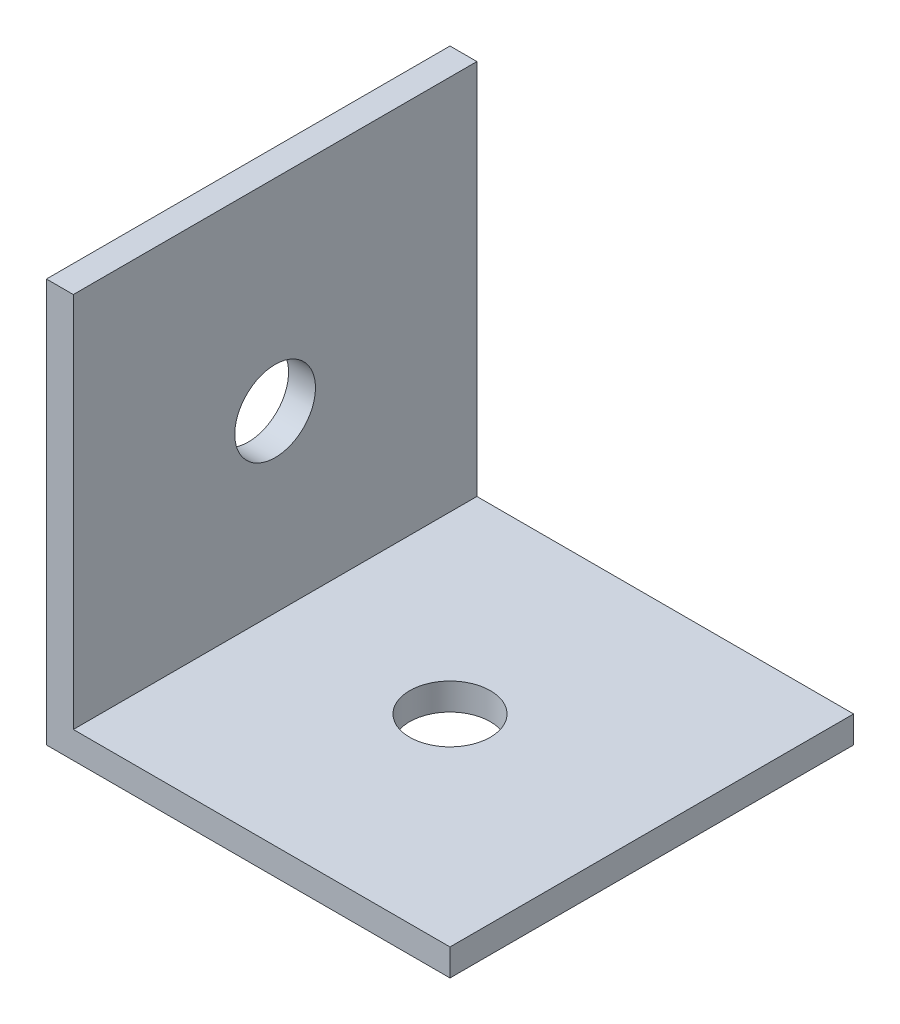
from build123d import *

# Parameters (mm, degrees)
EXTRUDE_1_DEPTH     = 15
SKETCH_2_R          = 1.5
CUT_EXTRUDE_1_DEPTH = 10
SKETCH_3_R          = 1.5
CUT_EXTRUDE_2_DEPTH = 10


with BuildPart() as part:
    # ｽｹｯﾁ1 → ﾎﾞｽ - 押し出し1 (new body)
    with BuildSketch(Plane.XY):
        Polygon((-4.461455774, 6.353305785), (-5.461455774, 6.353305785), (-5.461455774, -8.646694215), (9.538544226, -8.646694215), (9.538544226, -7.646694215), (-4.461455774, -7.646694215), align=None)
    extrude(amount=EXTRUDE_1_DEPTH)

    # ｽｹｯﾁ2 → ｶｯﾄ - 押し出し1 (cut)
    with BuildSketch(Plane.ZY.offset(5.461455774)):
        with Locations((7.5, -1.146694215)):
            Circle(SKETCH_2_R)
    extrude(amount=-CUT_EXTRUDE_1_DEPTH, mode=Mode.SUBTRACT)

    # ｽｹｯﾁ3 → ｶｯﾄ - 押し出し2 (cut)
    with BuildSketch(Plane.XZ.offset(8.646694215)):
        with Locations((2.038544226, 7.5)):
            Circle(SKETCH_3_R)
    extrude(amount=-CUT_EXTRUDE_2_DEPTH, mode=Mode.SUBTRACT)


solid = part.part
